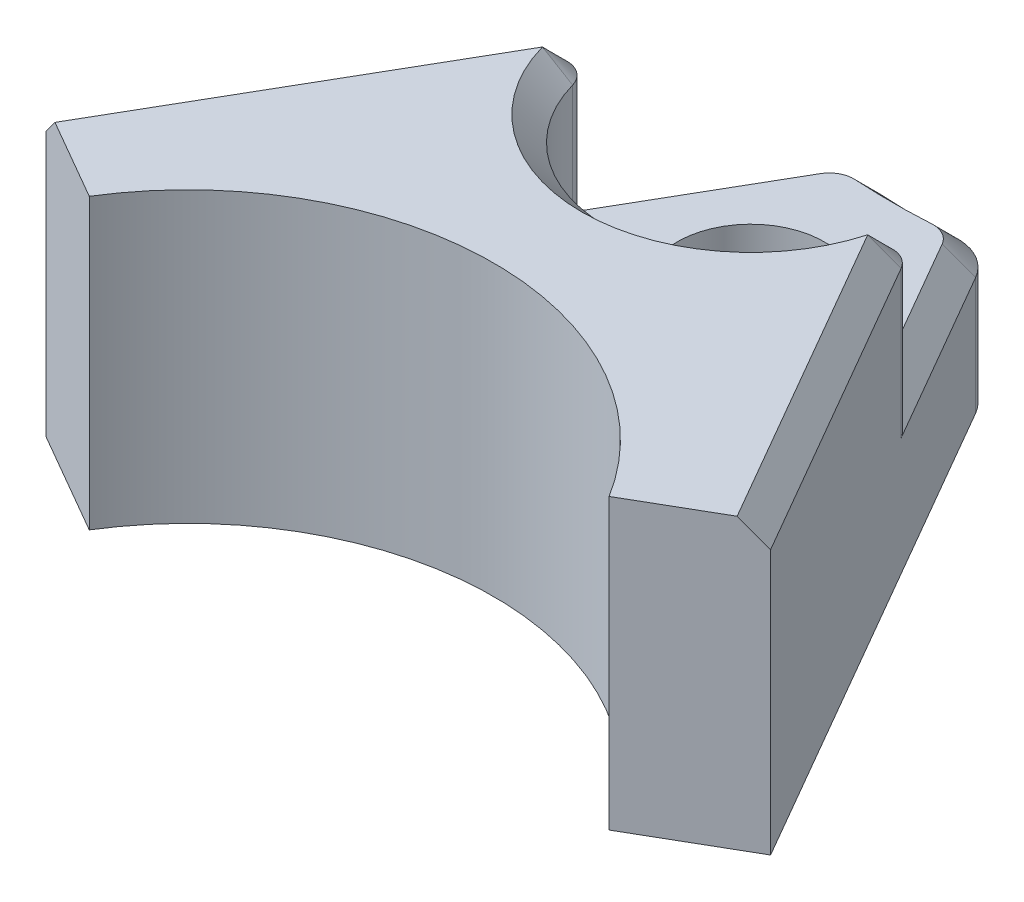
from build123d import *

# Parameters (mm, degrees)
SKETCH1_R                = 1.5
BASE_DEPTH               = 5.9
FASTENER_CLEARANCE_DEPTH = 3
FASTENER_FILLET_R        = 0.5
BASE_FILLET_R            = 1
BODY_CHAMFER_SIZE        = 0.5


with BuildPart() as part:
    # Sketch1 → Base (new body)
    with BuildSketch(Plane(origin=(0, 0, 0), x_dir=(1, 0, 0), z_dir=(0, 1, 0))):
        with BuildLine():
            Line((5.307777313, 3.3), (7.397782409, 4.506665005))
            Line((7.397782409, 4.506665005), (1.360112218, 14.964216534))
            ThreePointArc((1.360112218, 14.964216534), (0, 14.89), (-1.360112218, 14.964216534))
            Line((-1.360112218, 14.964216534), (-7.397782409, 4.506665005))
            Line((-7.397782409, 4.506665005), (-5.307777313, 3.3))
            ThreePointArc((-5.307777313, 3.3), (0, 6.25), (5.307777313, 3.3))
        make_face()
        with Locations((0, 11.5)):
            Circle(SKETCH1_R, mode=Mode.SUBTRACT)
    extrude(amount=BASE_DEPTH)

    # Sketch2 → Fastener Clearance (cut)
    with BuildSketch(Plane(origin=(0, 5.9, 0), x_dir=(1, 0, 0), z_dir=(0, 1, 0))):
        with BuildLine():
            Line((-2.762208294, 12.535714894), (-1.360112218, 14.964216534))
            ThreePointArc((-1.360112218, 14.964216534), (0, 14.89), (1.360112218, 14.964216534))
            Line((1.360112218, 14.964216534), (2.762208294, 12.535714894))
            ThreePointArc((2.762208294, 12.535714894), (0, 8.55), (-2.762208294, 12.535714894))
        make_face()
    extrude(amount=-FASTENER_CLEARANCE_DEPTH, mode=Mode.SUBTRACT)

    # Fastener Fillet
    fastener_fillet_edges = [part.edges().sort_by_distance(p)[0] for p in [
        (2.762208294, 4.4, -12.535714894),
        (-2.762208294, 4.4, -12.535714894),
    ]]
    fillet(fastener_fillet_edges, radius=FASTENER_FILLET_R)

    # Base Fillet
    base_fillet_edges = [part.edges().sort_by_distance(p)[0] for p in [
        (-1.360112218, 1.45, -14.964216534),
        (1.360112218, 1.45, -14.964216534),
    ]]
    fillet(base_fillet_edges, radius=BASE_FILLET_R)

    # Body Chamfer
    body_chamfer_edges = [part.edges().sort_by_distance(p)[0] for p in [
        (5.576129132, 5.9, -7.661861034),
        (2.219874831, 2.9, -13.475064006),
        (0, 5.9, -8.55),
        (-5.576129132, 5.9, -7.661861034),
        (-3.259182505, 5.9, -11.063163021),
        (3.259182505, 5.9, -11.063163021),
        (-2.219874831, 2.9, -13.475064006),
        (0, 2.9, -14.89),
        (1.285248704, 2.9, -14.795081779),
        (-1.285248704, 2.9, -14.795081779),
    ]]
    chamfer(body_chamfer_edges, length=BODY_CHAMFER_SIZE)


solid = part.part
